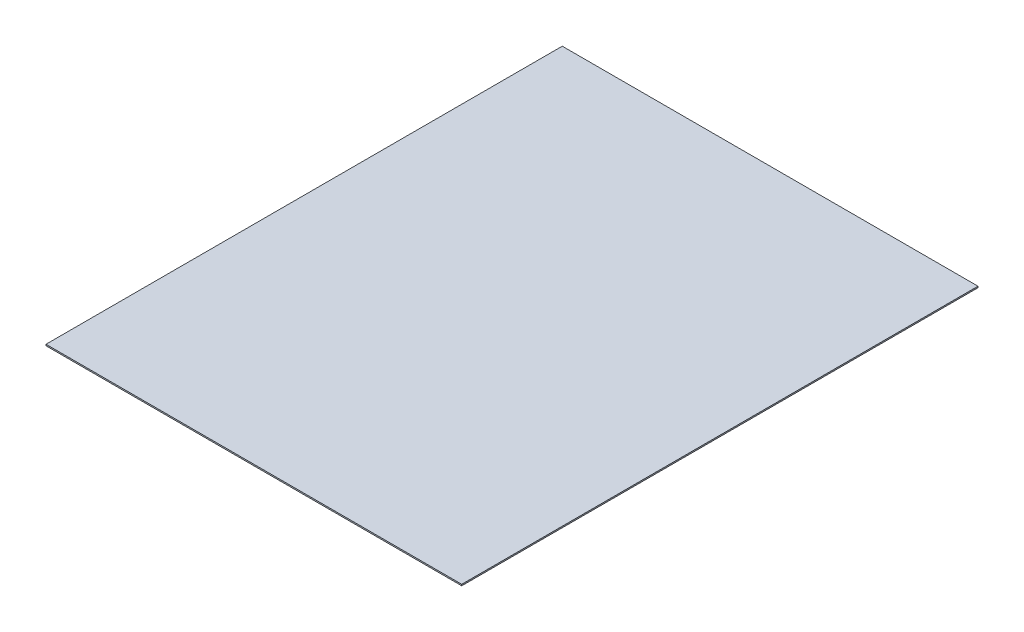
from build123d import *

# Parameters (mm, degrees)
SKETCH1_W           = 306
SKETCH1_H           = 380
BOSS_EXTRUDE1_DEPTH = 1


with BuildPart() as part:
    # Sketch1 → Boss-Extrude1 (new body)
    with BuildSketch(Plane(origin=(0, 0, 0), x_dir=(1, 0, 0), z_dir=(0, 1, 0))):
        with Locations((-195.152577929, -19.84451151)):
            Rectangle(SKETCH1_W, SKETCH1_H)
    extrude(amount=BOSS_EXTRUDE1_DEPTH)


solid = part.part
